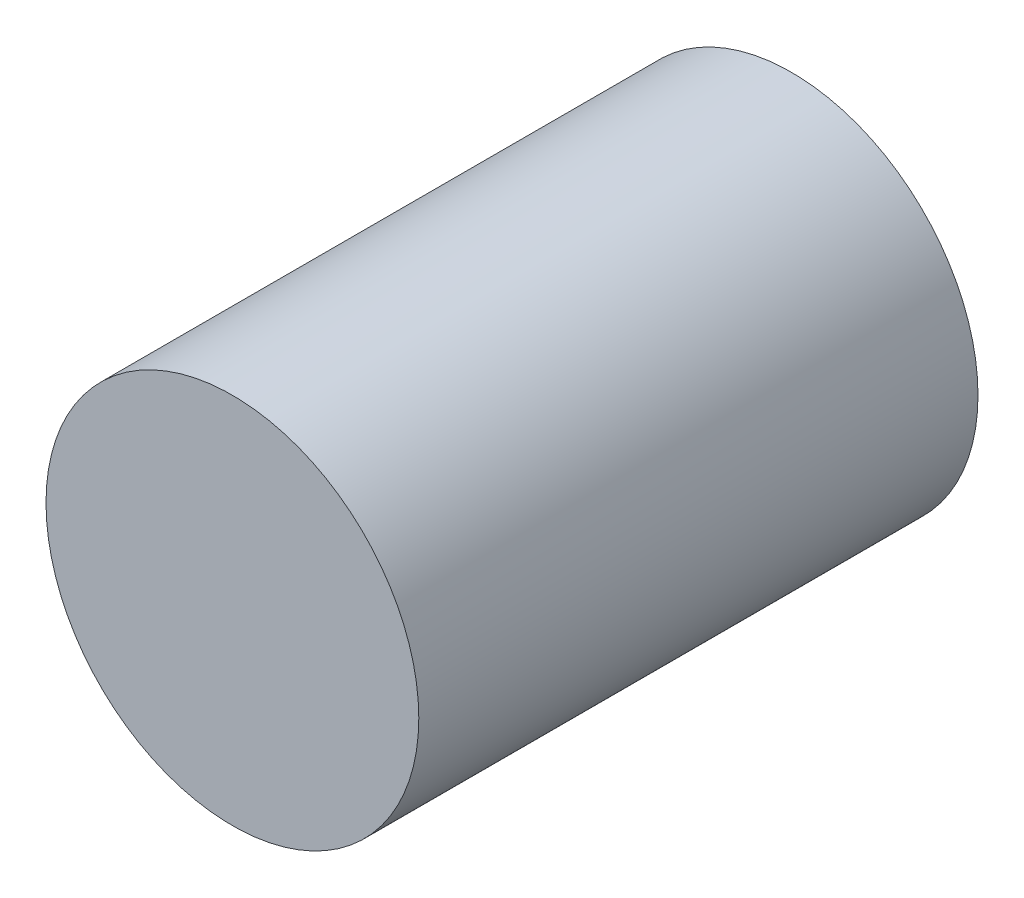
from build123d import *

# Parameters (mm, degrees)
SKETCH1_R           = 25
BOSS_EXTRUDE1_DEPTH = 37.5


with BuildPart() as part:
    # Sketch1 → Boss-Extrude1 (new body, symmetric)
    with BuildSketch(Plane.XY):
        Circle(SKETCH1_R)
    extrude(amount=BOSS_EXTRUDE1_DEPTH, both=True)


solid = part.part
